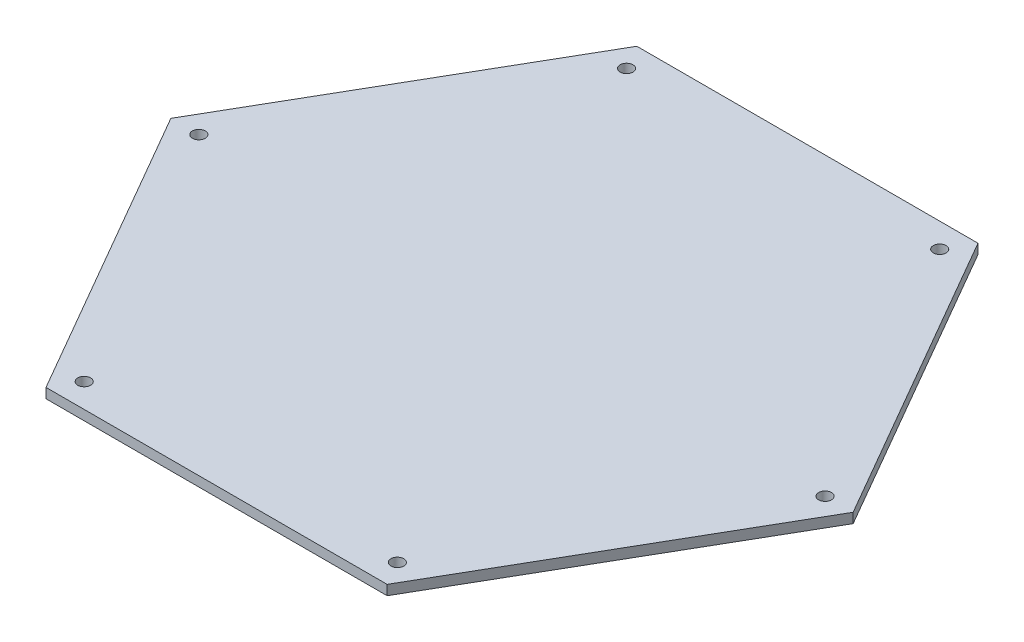
from build123d import *

# Parameters (mm, degrees)
BOSS_EXTRUDE1_DEPTH = 2.54
SKETCH2_R           = 1.651
CUT_EXTRUDE1_DEPTH  = 3.54
CIRPATTERN1_COUNT   = 6


with BuildPart() as part:
    # Sketch1 → Boss-Extrude1 (new body)
    with BuildSketch(Plane(origin=(0, 0, 0), x_dir=(1, 0, 0), z_dir=(0, 1, 0))):
        Polygon((43.884105286, -76.0095), (87.768210572, 0), (43.884105286, 76.0095), (-43.884105286, 76.0095), (-87.768210572, 0), (-43.884105286, -76.0095), align=None)
    extrude(amount=BOSS_EXTRUDE1_DEPTH)

    # Sketch2 → Cut-Extrude1 (cut, through all)
    with BuildSketch(Plane(origin=(0, 2.54, 0), x_dir=(1, 0, 0), z_dir=(0, 1, 0))):
        with Locations((-40.264605286, 69.740342102)):
            Circle(SKETCH2_R)
    cut_extrude1 = extrude(amount=-CUT_EXTRUDE1_DEPTH, mode=Mode.SUBTRACT)

    # CirPattern1: Cut-Extrude1 ×6 about axis
    cirpattern1_axis = Axis((0.017235622, 0, 0.029852973), (0, 1, 0))
    for i in range(1, CIRPATTERN1_COUNT):
        add(cut_extrude1.rotate(cirpattern1_axis, i * 360 / CIRPATTERN1_COUNT), mode=Mode.SUBTRACT)


solid = part.part
